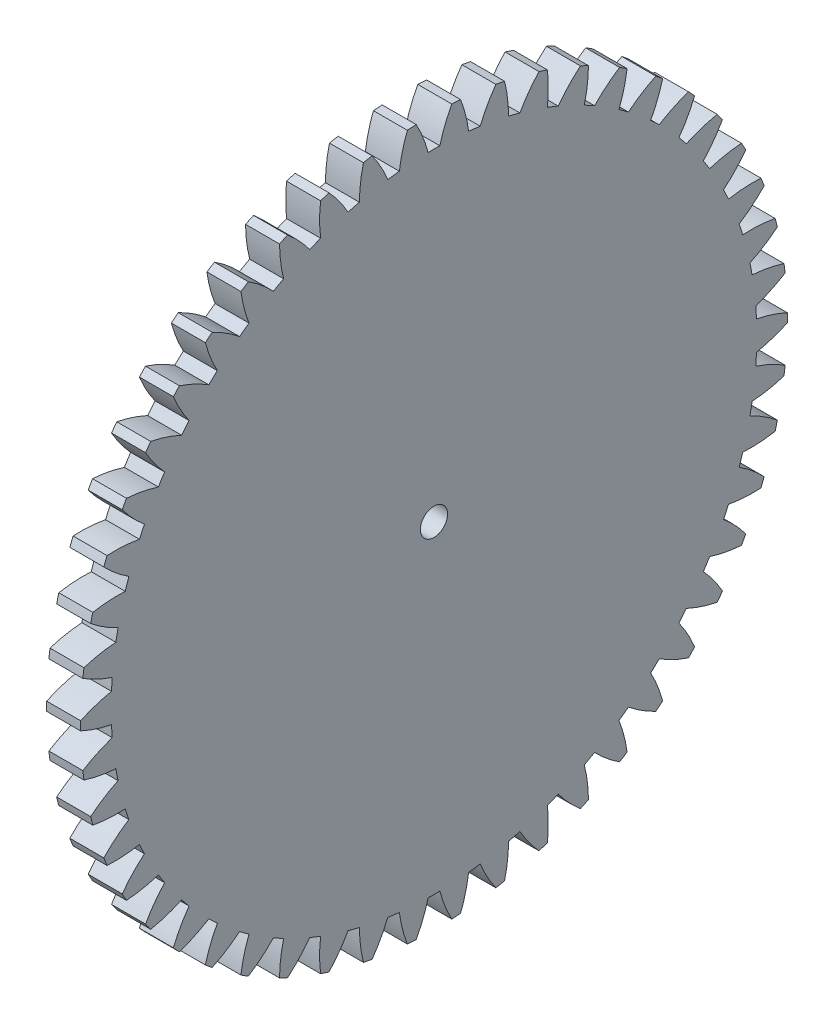
from build123d import *

# Parameters (mm, degrees)
BASPROSKE_W             = 10
BASPROSKE_H             = 52
TOOTHCUT_DEPTH          = 75.215901261
TEETHCUTS_COUNT         = 50
TEETHCUTS_ANGLE         = 352.8
HUBNEAONESKE_R          = 25
HUBNEARONE_DEPTH        = 10.0000508
BORSKE_R                = 2
BORE_DEPTH              = 20.0000508
ESQUISSE1_R             = 25
ENL_V_MAT_EXTRU_1_DEPTH = 5
ESQUISSE2_R             = 52
ENL_V_MAT_EXTRU_2_DEPTH = 5


with BuildPart() as part:
    # BasProSke → Base-Revolve (revolve)
    with BuildSketch(Plane(origin=(0, 0, 0), x_dir=(1, 0, 0), z_dir=(0, 1, 0)), mode=Mode.PRIVATE) as base_revolve_sk:
        with Locations((5, 26)):
            Rectangle(BASPROSKE_W, BASPROSKE_H)
    revolve(base_revolve_sk.sketch.rotate(Axis((-10, 0, 0), (1, 0, 0)), 180), axis=Axis((-10, 0, 0), (1, 0, 0)))

    # TooCutSke → ToothCut (cut, through all)
    with BuildSketch(Plane(origin=(0, 0, 0), x_dir=(0, 0, -1), z_dir=(1, 0, 0))):
        with BuildLine():
            ThreePointArc((0.86062222, 47.491202663), (0, 47.499), (-0.86062222, 47.491202663))
            ThreePointArc((-0.86062222, 47.491202663), (-1.610166517, 49.778366785), (-2.629027787, 51.958930494))
            ThreePointArc((-2.629027787, 51.958930494), (0, 52.0254), (2.629027787, 51.958930494))
            ThreePointArc((2.629027787, 51.958930494), (1.610166517, 49.778366785), (0.86062222, 47.491202663))
        make_face()
    toothcut = extrude(amount=TOOTHCUT_DEPTH, mode=Mode.SUBTRACT)

    # TeethCuts: ToothCut ×50 about axis
    teethcuts_axis = Axis((-10, 0, 0), (1, 0, 0))
    for i in range(1, TEETHCUTS_COUNT):
        add(toothcut.rotate(teethcuts_axis, i * TEETHCUTS_ANGLE / (TEETHCUTS_COUNT - 1)), mode=Mode.SUBTRACT)

    # HubNeaOneSke → HubNearOne (add)
    with BuildSketch(Plane.ZY):
        with Locations(Location((0, 0, 0), (0, 0, 180))):
            Circle(HUBNEAONESKE_R)
    extrude(amount=HUBNEARONE_DEPTH)

    # BorSke → Bore (cut, symmetric)
    with BuildSketch(Plane(origin=(0, 0, 0), x_dir=(0, 0, -1), z_dir=(1, 0, 0))):
        with Locations(Location((0, 0, 0), (0, 0, 180))):
            Circle(BORSKE_R)
    extrude(amount=BORE_DEPTH, both=True, mode=Mode.SUBTRACT)

    # Esquisse1 → Enlèv. mat.-Extru.1 (cut)
    with BuildSketch(Plane.ZY.offset(10.0000508)):
        with Locations(Location((0, 0, 0), (0, 0, 180))):
            Circle(ESQUISSE1_R)
    extrude(amount=-ENL_V_MAT_EXTRU_1_DEPTH, mode=Mode.SUBTRACT)

    # Esquisse2 → Enlèv. mat.-Extru.2 (cut)
    with BuildSketch(Plane(origin=(10, 0, 0), x_dir=(0, 0, -1), z_dir=(1, 0, 0))):
        Circle(ESQUISSE2_R)
    extrude(amount=-ENL_V_MAT_EXTRU_2_DEPTH, mode=Mode.SUBTRACT)


solid = part.part
